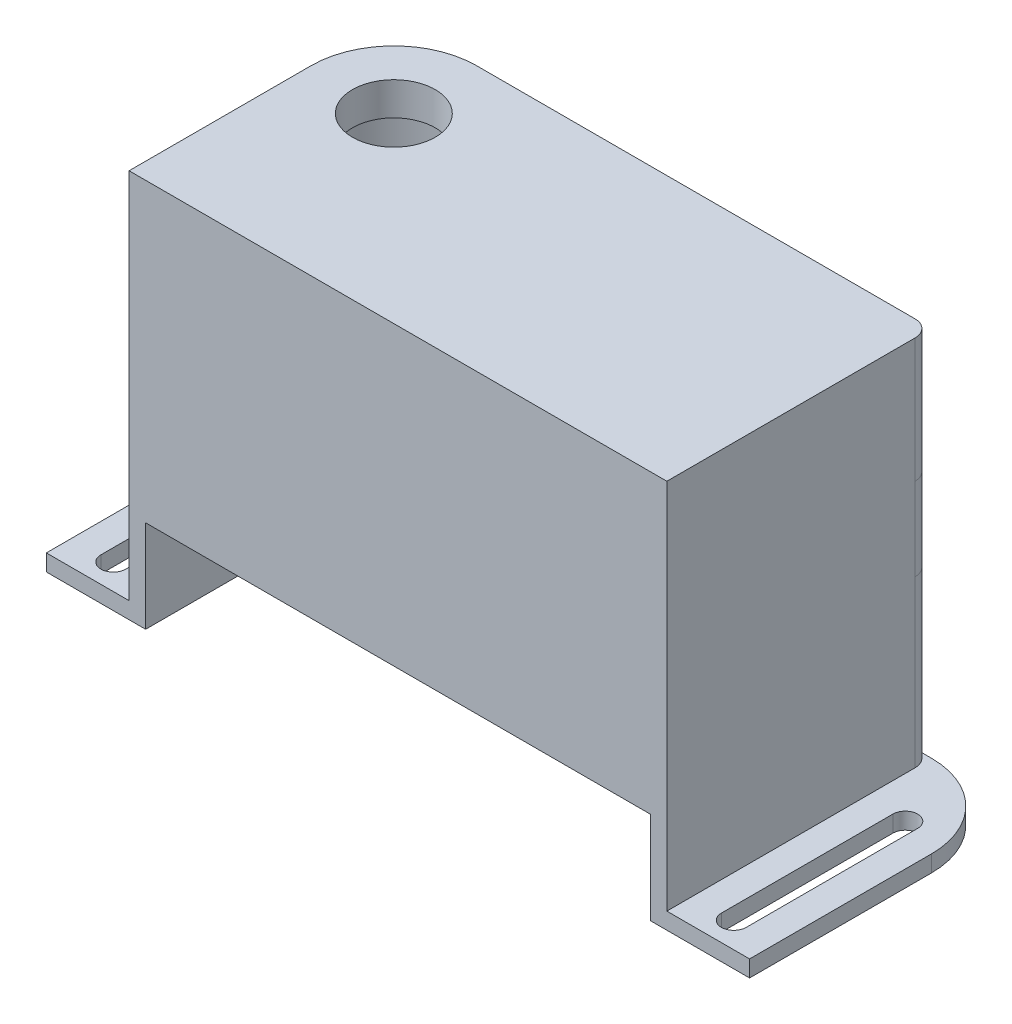
from build123d import *

# Parameters (mm, degrees)
SKETCH2_W           = 85
SKETCH2_H           = 32
BOSS_EXTRUDE1_DEPTH = 2
SKETCH3_W           = 65
SKETCH3_H           = 32
BOSS_EXTRUDE2_DEPTH = 45
SKETCH4_W           = 61
SKETCH4_H           = 28
CUT_EXTRUDE1_DEPTH  = 43
FILLET1_R           = 10
FILLET2_R           = 2
FILLET3_R           = 10
FILLET4_R           = 10
FILLET5_R           = 10
FILLET6_R           = 2
SKETCH5_W           = 61
SKETCH5_H           = 22.301239178
CUT_EXTRUDE2_DEPTH  = 10
CUT_EXTRUDE3_DEPTH  = 10
SKETCH7_R           = 5
CUT_EXTRUDE4_DEPTH  = 10
SKETCH8_W           = 5
SKETCH8_H           = 12
SKETCH8_W_2         = 7
BOSS_EXTRUDE3_DEPTH = 10
FILLET8_R           = 2
SKETCH9_R           = 1
CUT_EXTRUDE5_DEPTH  = 10
SKETCH10_W          = 3
SKETCH10_H          = 10
BOSS_EXTRUDE4_DEPTH = 10
SKETCH11_W          = 8
SKETCH11_H          = 6
CUT_EXTRUDE6_DEPTH  = 5


with BuildPart() as part:
    # Sketch2 → Boss-Extrude1 (new body)
    with BuildSketch(Plane(origin=(0, 0, 0), x_dir=(1, 0, 0), z_dir=(0, 1, 0))):
        Rectangle(SKETCH2_W, SKETCH2_H)
    extrude(amount=BOSS_EXTRUDE1_DEPTH)

    # Sketch3 → Boss-Extrude2 (add)
    with BuildSketch(Plane(origin=(0, 2, 0), x_dir=(1, 0, 0), z_dir=(0, 1, 0))):
        Rectangle(SKETCH3_W, SKETCH3_H)
    extrude(amount=BOSS_EXTRUDE2_DEPTH)

    # Sketch4 → Cut-Extrude1 (cut)
    with BuildSketch(Plane.XZ):
        Rectangle(SKETCH4_W, SKETCH4_H)
    extrude(amount=-CUT_EXTRUDE1_DEPTH, mode=Mode.SUBTRACT)

    # Fillet1
    fillet1_edges = [part.edges().sort_by_distance(p)[0] for p in [
        (-32.5, 24.5, -16),
    ]]
    fillet(fillet1_edges, radius=FILLET1_R)

    # Fillet2
    fillet2_edges = [part.edges().sort_by_distance(p)[0] for p in [
        (32.5, 24.5, -16),
    ]]
    fillet(fillet2_edges, radius=FILLET2_R)

    # Fillet3
    fillet3_edges = [part.edges().sort_by_distance(p)[0] for p in [
        (-42.5, 1, -16),
    ]]
    fillet(fillet3_edges, radius=FILLET3_R)

    # Fillet4
    fillet4_edges = [part.edges().sort_by_distance(p)[0] for p in [
        (42.5, 1, -16),
    ]]
    fillet(fillet4_edges, radius=FILLET4_R)

    # Fillet5
    fillet5_edges = [part.edges().sort_by_distance(p)[0] for p in [
        (-30.5, 21.5, -14),
    ]]
    fillet(fillet5_edges, radius=FILLET5_R)

    # Fillet6
    fillet6_edges = [part.edges().sort_by_distance(p)[0] for p in [
        (30.5, 21.5, -14),
    ]]
    fillet(fillet6_edges, radius=FILLET6_R)

    # Sketch5 → Cut-Extrude2 (cut)
    with BuildSketch(Plane.XY.offset(16)):
        Rectangle(SKETCH5_W, SKETCH5_H)
    extrude(amount=-CUT_EXTRUDE2_DEPTH, mode=Mode.SUBTRACT)

    # Sketch6 → Cut-Extrude3 (cut)
    with BuildSketch(Plane(origin=(0, 2, 0), x_dir=(1, 0, 0), z_dir=(0, 1, 0))):
        with BuildLine():
            Line((39, 7.816649024), (39, -12.904408744))
            ThreePointArc((39, -12.904408744), (37.5, -14.404408744), (36, -12.904408744))
            Line((36, -12.904408744), (36, 7.816649024))
            ThreePointArc((36, 7.816649024), (37.5, 9.316649024), (39, 7.816649024))
        make_face()
        with BuildLine():
            Line((-36, 7.816649024), (-36, -12.904408744))
            ThreePointArc((-36, -12.904408744), (-37.5, -14.404408744), (-39, -12.904408744))
            Line((-39, -12.904408744), (-39, 7.816649024))
            ThreePointArc((-39, 7.816649024), (-37.5, 9.316649024), (-36, 7.816649024))
        make_face()
    extrude(amount=-CUT_EXTRUDE3_DEPTH, mode=Mode.SUBTRACT)

    # Sketch7 → Cut-Extrude4 (cut)
    with BuildSketch(Plane(origin=(0, 47, 0), x_dir=(1, 0, 0), z_dir=(0, 1, 0))):
        with Locations((-22.5, 6)):
            Circle(SKETCH7_R)
    extrude(amount=-CUT_EXTRUDE4_DEPTH, mode=Mode.SUBTRACT)

    # Sketch8 → Boss-Extrude3 (add)
    with BuildSketch(Plane(origin=(0, 22, 0), x_dir=(1, 0, 0), z_dir=(0, 1, 0))):
        with Locations((1, 10)):
            Rectangle(SKETCH8_W, SKETCH8_H)
        with Locations((29, 10)):
            Rectangle(SKETCH8_W_2, SKETCH8_H)
    extrude(amount=BOSS_EXTRUDE3_DEPTH)

    # Fillet8
    fillet8_edges = [part.edges().sort_by_distance(p)[0] for p in [
        (32.5, 27, -16),
    ]]
    fillet(fillet8_edges, radius=FILLET8_R)

    # Sketch9 → Cut-Extrude5 (cut)
    with BuildSketch(Plane.XZ.offset(-22)):
        with Locations((1, -8)):
            Circle(SKETCH9_R)
        with Locations((28, -8)):
            Circle(SKETCH9_R)
    extrude(amount=-CUT_EXTRUDE5_DEPTH, mode=Mode.SUBTRACT)

    # Sketch10 → Boss-Extrude4 (add)
    with BuildSketch(Plane.XY.offset(-14)):
        with Locations((-6.587930701, 27)):
            Rectangle(SKETCH10_W, SKETCH10_H)
    extrude(amount=BOSS_EXTRUDE4_DEPTH)

    # Sketch11 → Cut-Extrude6 (cut)
    with BuildSketch(Plane.ZY.offset(8.087930701)):
        with Locations((-10, 27)):
            Rectangle(SKETCH11_W, SKETCH11_H)
    extrude(amount=-CUT_EXTRUDE6_DEPTH, mode=Mode.SUBTRACT)


solid = part.part
